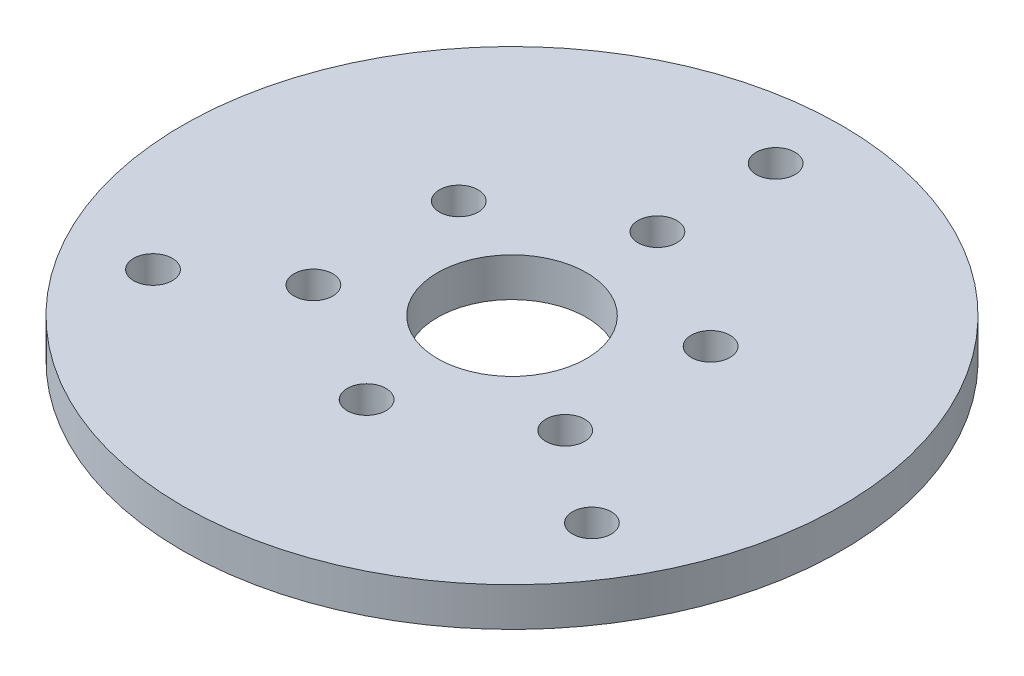
from build123d import *

# Parameters (mm, degrees)
SKETCH1_R           = 53.975
SKETCH1_R_2         = 3.175
BOSS_EXTRUDE1_DEPTH = 6.35
SKETCH2_R           = 3.175
SKETCH2_R_2         = 12.2
CUT_EXTRUDE1_DEPTH  = 7.35


with BuildPart() as part:
    # Sketch1 → Boss-Extrude1 (new body)
    with BuildSketch(Plane(origin=(0, 0, 0), x_dir=(1, 0, 0), z_dir=(0, 1, 0))):
        Circle(SKETCH1_R)
        with Locations((0, 43.18)):
            Circle(SKETCH1_R_2, mode=Mode.SUBTRACT)
        with Locations((35.941, -22.86)):
            Circle(SKETCH1_R_2, mode=Mode.SUBTRACT)
        with Locations((-35.941, -22.86)):
            Circle(SKETCH1_R_2, mode=Mode.SUBTRACT)
    extrude(amount=BOSS_EXTRUDE1_DEPTH)

    # Sketch2 → Cut-Extrude1 (cut, through all)
    with BuildSketch(Plane(origin=(0, 6.35, 0), x_dir=(1, 0, 0), z_dir=(0, 1, 0))):
        with Locations((0, 23.8125)):
            Circle(SKETCH2_R)
        with Locations((20.622229928, 11.90625)):
            Circle(SKETCH2_R)
        with Locations((20.622229928, -11.90625)):
            Circle(SKETCH2_R)
        with Locations((0, -23.8125)):
            Circle(SKETCH2_R)
        with Locations((-20.622229928, -11.90625)):
            Circle(SKETCH2_R)
        with Locations((-20.622229928, 11.90625)):
            Circle(SKETCH2_R)
        Circle(SKETCH2_R_2)
    extrude(amount=-CUT_EXTRUDE1_DEPTH, mode=Mode.SUBTRACT)


solid = part.part
